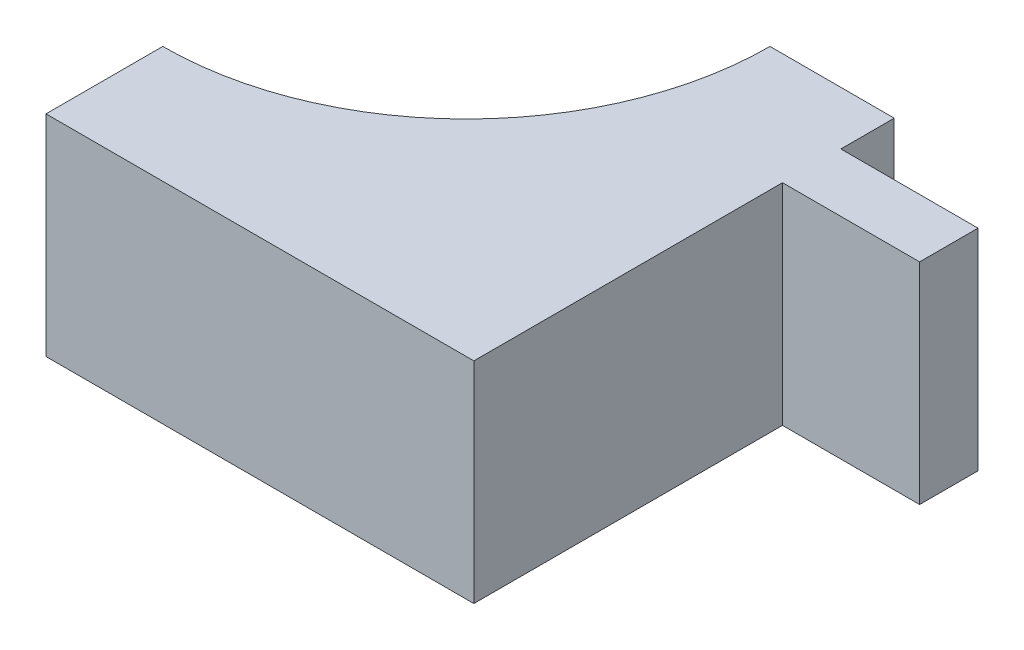
from build123d import *

# Parameters (mm, degrees)
BOSS_EXTRUDE1_DEPTH = 18


with BuildPart() as part:
    # Sketch1 → Boss-Extrude1 (new body)
    with BuildSketch(Plane(origin=(0, 0, 0), x_dir=(1, 0, 0), z_dir=(0, 1, 0))):
        with BuildLine():
            Line((-24, 305), (-13.36, 305))
            Line((-13.36, 305), (-13.36, 300.43))
            Line((-13.36, 300.43), (-1.616090732, 300.43))
            Line((-1.616090732, 300.43), (-1.616090732, 295.43))
            Line((-1.616090732, 295.43), (-13.36, 295.43))
            Line((-13.36, 295.43), (-13.36, 269))
            Line((-13.36, 269), (-50, 269))
            Line((-50, 269), (-50, 279))
            ThreePointArc((-50, 279), (-31.615223689, 286.615223689), (-24, 305))
        make_face()
    extrude(amount=BOSS_EXTRUDE1_DEPTH)


solid = part.part
